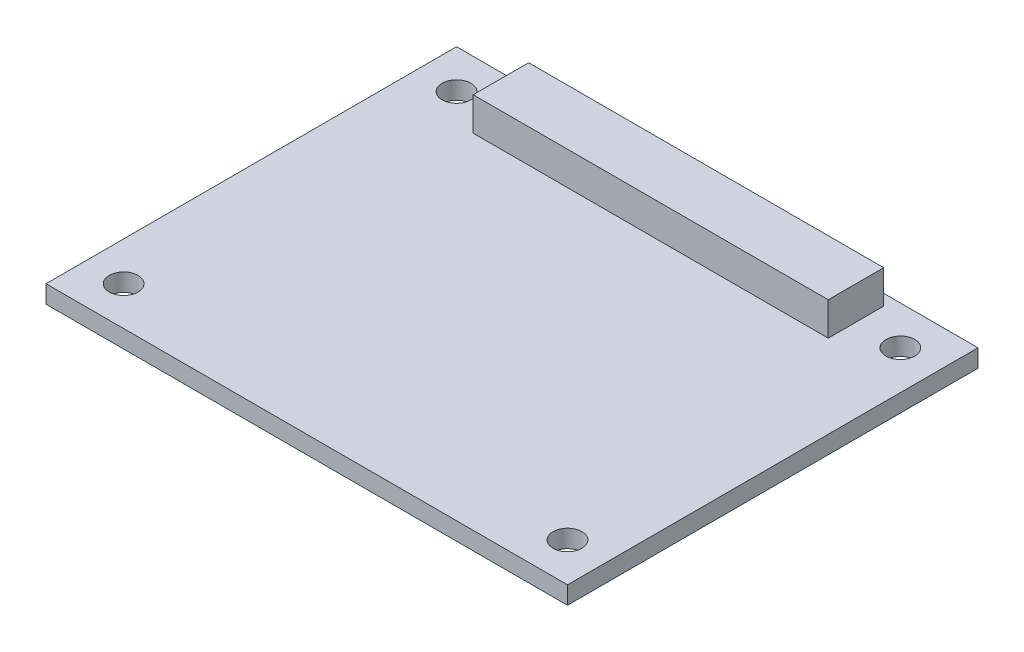
from build123d import *

# Parameters (mm, degrees)
SKETCH_1_W          = 47
SKETCH_1_H          = 37
EXTRUDE_1_DEPTH     = 1.6
SKETCH_2_R          = 1.3
CUT_EXTRUDE_1_DEPTH = 1.6
SKETCH_3_W          = 32
SKETCH_3_H          = 5
EXTRUDE_2_DEPTH     = 3


with BuildPart() as part:
    # Эскиз1 → Бобышка-Вытянуть1 (new body)
    with BuildSketch(Plane(origin=(0, 0, 0), x_dir=(1, 0, 0), z_dir=(0, 1, 0))):
        Rectangle(SKETCH_1_W, SKETCH_1_H)
    extrude(amount=-EXTRUDE_1_DEPTH)

    # Эскиз2 → Вырез-Вытянуть1 (cut)
    with BuildSketch(Plane(origin=(0, 0, 0), x_dir=(1, 0, 0), z_dir=(0, 1, 0))):
        with Locations((-20, 15)):
            Circle(SKETCH_2_R)
        with Locations((-20, -15)):
            Circle(SKETCH_2_R)
        with Locations((20, -15)):
            Circle(SKETCH_2_R)
        with Locations((20, 15)):
            Circle(SKETCH_2_R)
    extrude(amount=-CUT_EXTRUDE_1_DEPTH, mode=Mode.SUBTRACT)

    # Эскиз3 → Бобышка-Вытянуть2 (add)
    with BuildSketch(Plane(origin=(0, 0, 0), x_dir=(1, 0, 0), z_dir=(0, 1, 0))):
        with Locations((0, 15)):
            Rectangle(SKETCH_3_W, SKETCH_3_H)
    extrude(amount=EXTRUDE_2_DEPTH)


solid = part.part
